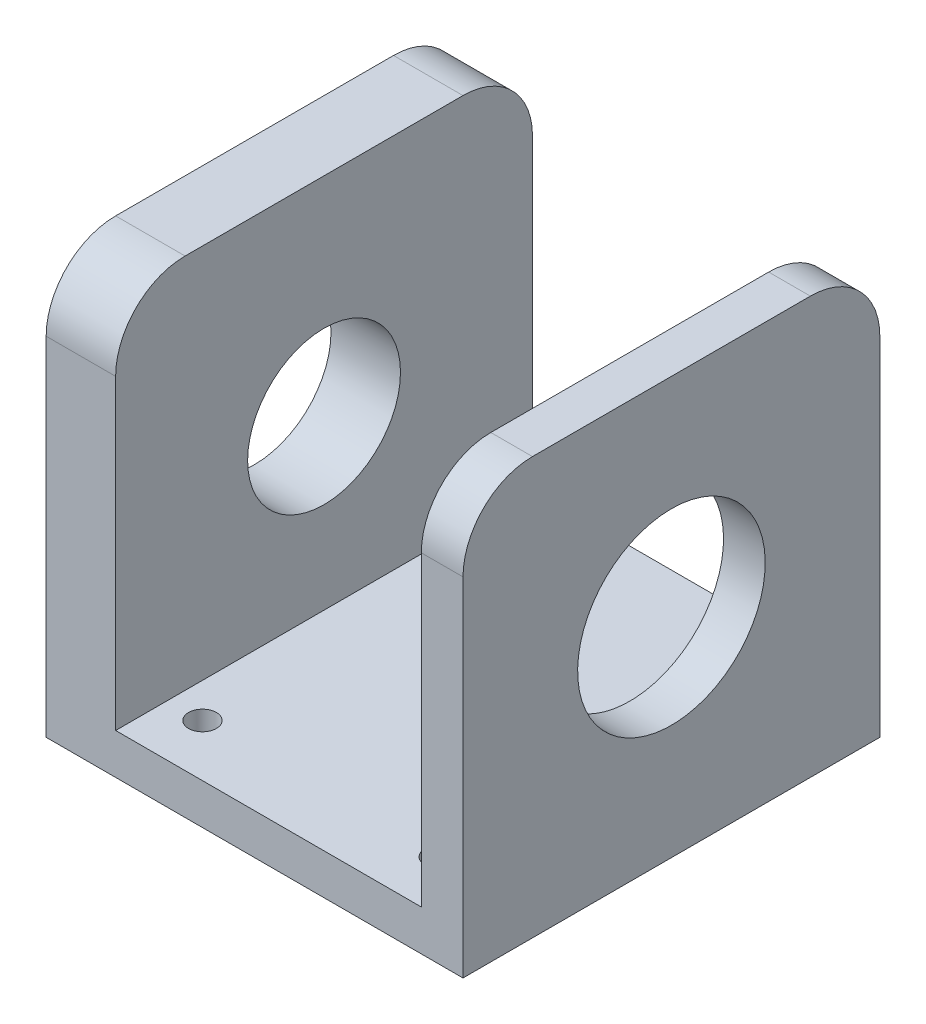
from build123d import *

# Parameters (mm, degrees)
BOSS_EXTRUDE1_DEPTH = 30
SKETCH2_R           = 11
CUT_EXTRUDE1_DEPTH  = 60
FILLET1_R           = 10
SKETCH3_R           = 2
CUT_EXTRUDE2_DEPTH  = 10
SKETCH13_R          = 13.5
CUT_EXTRUDE3_DEPTH  = 10


with BuildPart() as part:
    # Sketch1 → Boss-Extrude1 (new body, symmetric)
    with BuildSketch(Plane.XY):
        Polygon((-30, 30), (-30, -30), (30, -30), (30, 30), (24, 30), (24, -24.147945483), (-20, -24.147945483), (-20, 30), align=None)
    extrude(amount=BOSS_EXTRUDE1_DEPTH, both=True)

    # Sketch2 → Cut-Extrude1 (cut)
    with BuildSketch(Plane(origin=(0, 0, 0), x_dir=(0, 0, -1), z_dir=(1, 0, 0))):
        Circle(SKETCH2_R)
    extrude(amount=-CUT_EXTRUDE1_DEPTH, mode=Mode.SUBTRACT)

    # Fillet1
    fillet1_edges = [part.edges().sort_by_distance(p)[0] for p in [
        (-25, 30, -30),
        (27, 30, 30),
        (-25, 30, 30),
        (27, 30, -30),
    ]]
    fillet(fillet1_edges, radius=FILLET1_R)

    # Sketch3 → Cut-Extrude2 (cut, symmetric)
    with BuildSketch(Plane(origin=(0, -24.147945483, 0), x_dir=(1, 0, 0), z_dir=(0, 1, 0))):
        with Locations((-15, 22.5)):
            Circle(SKETCH3_R)
        with Locations((19, 22.5)):
            Circle(SKETCH3_R)
        with Locations((-15, -22.5)):
            Circle(SKETCH3_R)
        with Locations((19, -22.5)):
            Circle(SKETCH3_R)
    extrude(amount=CUT_EXTRUDE2_DEPTH, both=True, mode=Mode.SUBTRACT)

    # Sketch13 → Cut-Extrude3 (cut)
    with BuildSketch(Plane(origin=(30, 0, 0), x_dir=(0, 0, -1), z_dir=(1, 0, 0))):
        Circle(SKETCH13_R)
    extrude(amount=-CUT_EXTRUDE3_DEPTH, mode=Mode.SUBTRACT)


solid = part.part
